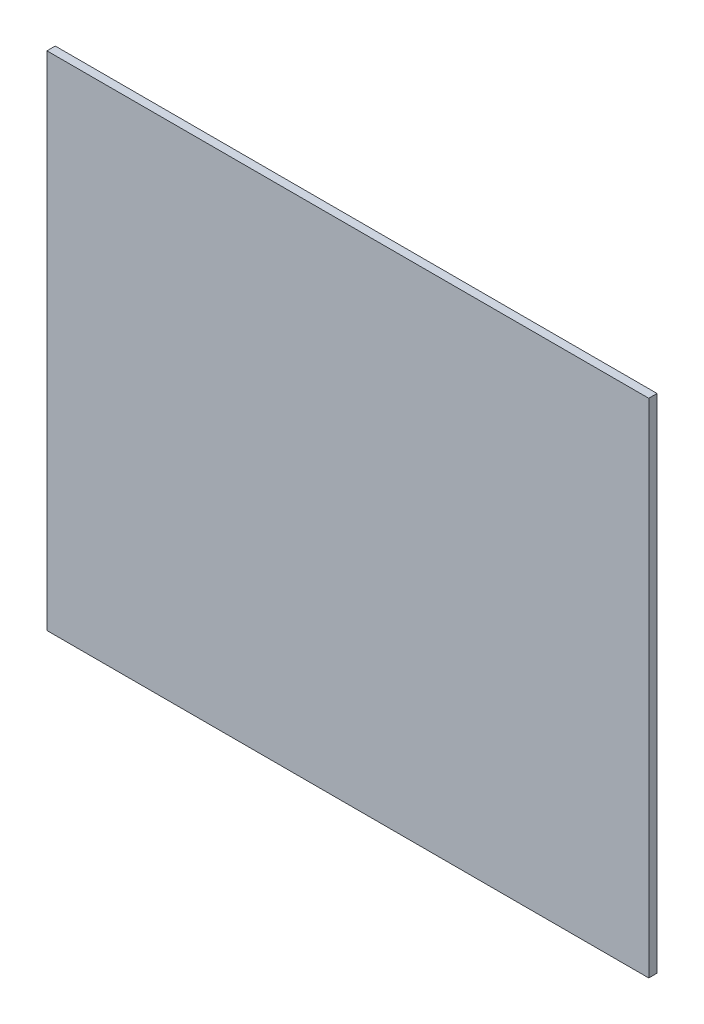
from build123d import *

# Parameters (mm, degrees)
SKETCH1_W           = 181
SKETCH1_H           = 2.5
BOSS_EXTRUDE1_DEPTH = 151


with BuildPart() as part:
    # Sketch1 → Boss-Extrude1 (new body)
    with BuildSketch(Plane(origin=(0, 0, 0), x_dir=(1, 0, 0), z_dir=(0, 1, 0))):
        with Locations((0, -22.25)):
            Rectangle(SKETCH1_W, SKETCH1_H)
    extrude(amount=BOSS_EXTRUDE1_DEPTH)


solid = part.part
